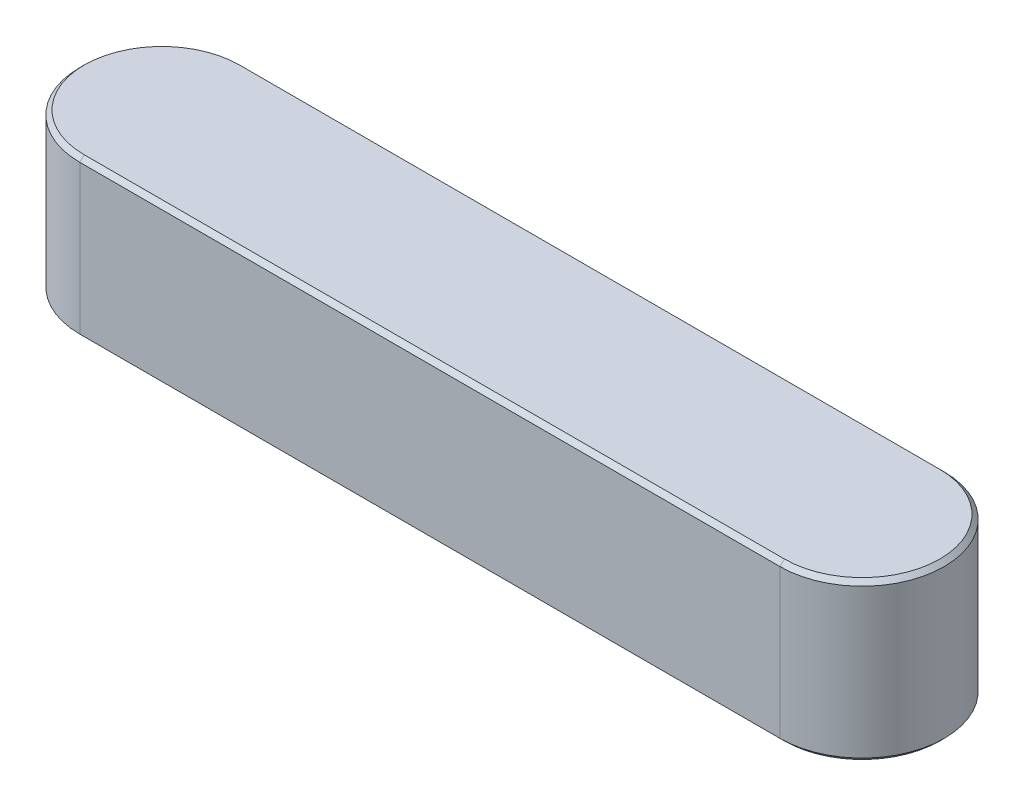
from build123d import *

# Parameters (mm, degrees)
BOSS_EXTRUDE1_DEPTH = 0.09
CHAMFER1_SIZE       = 0.005


with BuildPart() as part:
    # Sketch1 → Boss-Extrude1 (new body, symmetric)
    with BuildSketch(Plane(origin=(0, 0, 0), x_dir=(1, 0, 0), z_dir=(0, 1, 0))):
        with BuildLine():
            Line((0.4, -0.09375), (-0.4, -0.09375))
            ThreePointArc((-0.4, -0.09375), (-0.49375, 0), (-0.4, 0.09375))
            Line((-0.4, 0.09375), (0.4, 0.09375))
            ThreePointArc((0.4, 0.09375), (0.49375, 0), (0.4, -0.09375))
        make_face()
    extrude(amount=BOSS_EXTRUDE1_DEPTH, both=True)

    # Chamfer1
    chamfer1_edges = [part.edges().sort_by_distance(p)[0] for p in [
        (-0.49375, 0.09, 0),
        (0, 0.09, 0.09375),
        (0.49375, 0.09, 0),
        (0, -0.09, 0.09375),
        (-0.49375, -0.09, 0),
        (0, -0.09, -0.09375),
        (0.49375, -0.09, 0),
        (0, 0.09, -0.09375),
    ]]
    chamfer(chamfer1_edges, length=CHAMFER1_SIZE)


solid = part.part
